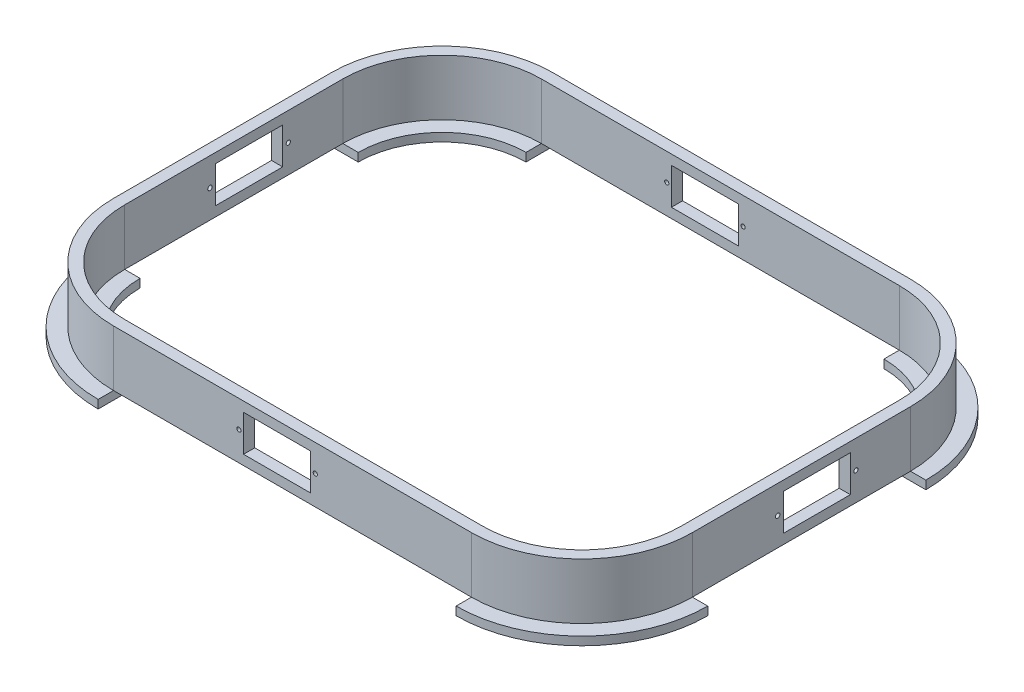
from build123d import *

# Parameters (mm, degrees)
BOSS_EXTRUDE1_DEPTH   = 3
BOSS_EXTRUDE1_2_DEPTH = 3
BOSS_EXTRUDE1_3_DEPTH = 3
BOSS_EXTRUDE1_4_DEPTH = 3
BOSS_EXTRUDE2_DEPTH   = 20
SKETCH3_W             = 24
SKETCH3_H             = 13
SKETCH3_R             = 6
SKETCH3_R_2           = 0.75
SKETCH3_R_3           = 0.8
CUT_EXTRUDE1_DEPTH    = 207
SKETCH4_W             = 24
SKETCH4_H             = 13
SKETCH4_R             = 6
SKETCH4_R_2           = 0.75
CUT_EXTRUDE3_DEPTH    = 157


with BuildPart() as part:
    # Sketch1 → Boss-Extrude1 (new body)
    with BuildSketch(Plane(origin=(0, 0, 0), x_dir=(1, 0, 0), z_dir=(0, 1, 0))):
        with BuildLine():
            ThreePointArc((-64, 84), (-95.819805153, 70.819805153), (-109, 39))
            Line((-109, 39), (-94, 39))
            ThreePointArc((-94, 39), (-85.213203436, 60.213203436), (-64, 69))
            Line((-64, 69), (-64, 84))
        make_face()
    extrude(amount=-BOSS_EXTRUDE1_DEPTH)



with BuildPart() as body_2:
    # Sketch1 → Boss-Extrude1 2 (new body)
    with BuildSketch(Plane(origin=(0, 0, 0), x_dir=(1, 0, 0), z_dir=(0, 1, 0))):
        with BuildLine():
            ThreePointArc((109, 39), (95.819805153, 70.819805153), (64, 84))
            Line((64, 84), (64, 69))
            ThreePointArc((64, 69), (85.213203436, 60.213203436), (94, 39))
            Line((94, 39), (109, 39))
        make_face()
    extrude(amount=-BOSS_EXTRUDE1_2_DEPTH)


with BuildPart() as body_3:
    # Sketch1 → Boss-Extrude1 3 (new body)
    with BuildSketch(Plane(origin=(0, 0, 0), x_dir=(1, 0, 0), z_dir=(0, 1, 0))):
        with BuildLine():
            ThreePointArc((-109, -39), (-95.819805153, -70.819805153), (-64, -84))
            Line((-64, -84), (-64, -69))
            ThreePointArc((-64, -69), (-85.213203436, -60.213203436), (-94, -39))
            Line((-94, -39), (-109, -39))
        make_face()
    extrude(amount=-BOSS_EXTRUDE1_3_DEPTH)


with BuildPart() as body_4:
    # Sketch1 → Boss-Extrude1 4 (new body)
    with BuildSketch(Plane(origin=(0, 0, 0), x_dir=(1, 0, 0), z_dir=(0, 1, 0))):
        with BuildLine():
            ThreePointArc((64, -84), (95.819805153, -70.819805153), (109, -39))
            Line((109, -39), (94, -39))
            ThreePointArc((94, -39), (85.213203436, -60.213203436), (64, -69))
            Line((64, -69), (64, -84))
        make_face()
    extrude(amount=-BOSS_EXTRUDE1_4_DEPTH)


with BuildPart() as part_1:
    add(part.part)

    add(body_2.part)  # Boss-Extrude2 merges body 2

    add(body_3.part)  # Boss-Extrude2 merges body 3

    add(body_4.part)  # Boss-Extrude2 merges body 4
    # Sketch1_6 → Boss-Extrude2 (add)
    with BuildSketch(Plane(origin=(0, 0, 0), x_dir=(1, 0, 0), z_dir=(0, 1, 0))):
        with BuildLine():
            Line((-64, 78.5), (64, 78.5))
            ThreePointArc((64, 78.5), (91.930717857, 66.930717857), (103.5, 39))
            Line((103.5, 39), (103.5, -39))
            ThreePointArc((103.5, -39), (91.930717857, -66.930717857), (64, -78.5))
            Line((64, -78.5), (-64, -78.5))
            ThreePointArc((-64, -78.5), (-91.930717857, -66.930717857), (-103.5, -39))
            Line((-103.5, -39), (-103.5, 39))
            ThreePointArc((-103.5, 39), (-91.930717857, 66.930717857), (-64, 78.5))
        make_face()
        with BuildLine():
            Line((-64, 74.5), (64, 74.5))
            ThreePointArc((64, 74.5), (89.102290732, 64.102290732), (99.5, 39))
            Line((99.5, 39), (99.5, -39))
            ThreePointArc((99.5, -39), (89.102290732, -64.102290732), (64, -74.5))
            Line((64, -74.5), (-64, -74.5))
            ThreePointArc((-64, -74.5), (-89.102290732, -64.102290732), (-99.5, -39))
            Line((-99.5, -39), (-99.5, 39))
            ThreePointArc((-99.5, 39), (-89.102290732, 64.102290732), (-64, 74.5))
        make_face(mode=Mode.SUBTRACT)
    extrude(amount=BOSS_EXTRUDE2_DEPTH)

    # Sketch3 → Cut-Extrude1 (cut)
    with BuildSketch(Plane.ZY.offset(103.5)):
        with Locations((-5.5, 10)):
            Rectangle(SKETCH3_W, SKETCH3_H)
        with Locations((0, 10)):
            Circle(SKETCH3_R, mode=Mode.SUBTRACT)
        with Locations((-19.5, 10)):
            Circle(SKETCH3_R_2)
        with Locations((0, 10)):
            Circle(SKETCH3_R)
        with Locations((8.5, 10)):
            Circle(SKETCH3_R_3)
    extrude(amount=-CUT_EXTRUDE1_DEPTH, mode=Mode.SUBTRACT)

    # Sketch4 → Cut-Extrude3 (cut)
    with BuildSketch(Plane.XY.offset(78.5)):
        with Locations((-5.5, 10)):
            Rectangle(SKETCH4_W, SKETCH4_H)
        with Locations((0, 10)):
            Circle(SKETCH4_R, mode=Mode.SUBTRACT)
        with Locations((-19.15, 10.35)):
            Circle(SKETCH4_R_2)
        with Locations((8.15, 10.35)):
            Circle(SKETCH4_R_2)
        with Locations((0, 10)):
            Circle(SKETCH4_R)
    extrude(amount=-CUT_EXTRUDE3_DEPTH, mode=Mode.SUBTRACT)


solid = part_1.part
